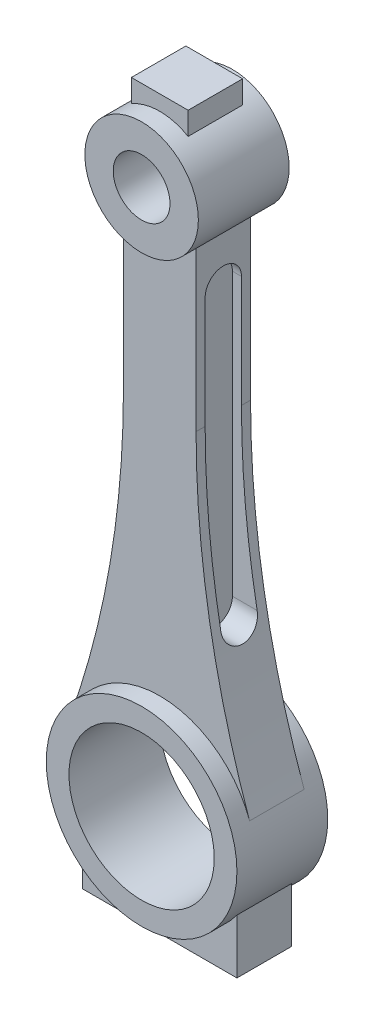
from build123d import *

# Parameters (mm, degrees)
SKETCH1_R             = 21
SKETCH1_R_2           = 16
BOSS_EXTRUDE2_DEPTH   = 10
SKETCH1_R_3           = 12.5
SKETCH1_R_4           = 6.25
BOSS_EXTRUDE2_2_DEPTH = 10
BOSS_EXTRUDE4_DEPTH   = 6
CUT_EXTRUDE1_START    = 6
CUT_EXTRUDE1_DEPTH    = 12


with BuildPart() as part:
    # Sketch1 → Boss-Extrude2 (new body, symmetric)
    with BuildSketch(Plane.XY):
        Circle(SKETCH1_R)
        Circle(SKETCH1_R_2, mode=Mode.SUBTRACT)
    extrude(amount=BOSS_EXTRUDE2_DEPTH, both=True)



with BuildPart() as body_2:
    # Sketch1 → Boss-Extrude2 2 (new body, symmetric)
    with BuildSketch(Plane.XY):
        with Locations((0, 120)):
            Circle(SKETCH1_R_3)
        with Locations((0, 120)):
            Circle(SKETCH1_R_4, mode=Mode.SUBTRACT)
    extrude(amount=BOSS_EXTRUDE2_2_DEPTH, both=True)


with BuildPart() as part_1:
    add(part.part)

    add(body_2.part)  # Boss-Extrude4 merges body 2
    # Sketch1_6 → Boss-Extrude4 (add, symmetric)
    with BuildSketch(Plane.XY):
        with BuildLine():
            Line((-8, 110.395313644), (-8, 75.395313644))
            ThreePointArc((-8, 75.395313644), (-10.96842855, 40.709642053), (-19.787382488, 7.032744434))
            ThreePointArc((-19.787382488, 7.032744434), (0, 21), (19.787382488, 7.032744434))
            ThreePointArc((19.787382488, 7.032744434), (10.96842855, 40.709642053), (8, 75.395313644))
            Line((8, 75.395313644), (8, 110.395313644))
            ThreePointArc((8, 110.395313644), (0, 107.5), (-8, 110.395313644))
        make_face()
        with BuildLine():
            Line((-6.25, 135.825317547), (-6.25, 130.825317547))
            ThreePointArc((-6.25, 130.825317547), (0, 132.5), (6.25, 130.825317547))
            Line((6.25, 130.825317547), (6.25, 135.825317547))
            Line((6.25, 135.825317547), (-6.25, 135.825317547))
        make_face()
        with BuildLine():
            ThreePointArc((17, -12.328828006), (0, -21), (-17, -12.328828006))
            Line((-17, -12.328828006), (-17, -24.328828006))
            Line((-17, -24.328828006), (17, -24.328828006))
            Line((17, -24.328828006), (17, -12.328828006))
        make_face()
    extrude(amount=BOSS_EXTRUDE4_DEPTH, both=True)

    # Sketch2 → Cut-Extrude1 (cut)
    with BuildSketch(Plane(origin=(0, 0, 0), x_dir=(0, 0, -1), z_dir=(1, 0, 0)).offset(CUT_EXTRUDE1_START)):
        with BuildLine():
            Line((4, 100), (4, 38))
            ThreePointArc((4, 38), (0, 34), (-4, 38))
            Line((-4, 38), (-4, 100))
            ThreePointArc((-4, 100), (0, 104), (4, 100))
        make_face()
    cut_extrude1 = extrude(amount=CUT_EXTRUDE1_DEPTH, mode=Mode.SUBTRACT)

    # Mirror1: Cut-Extrude1 across plane
    add(cut_extrude1.mirror(Plane(origin=(0, 0, 0), x_dir=(0, 0, 1), z_dir=(1, 0, 0))), mode=Mode.SUBTRACT)


solid = part_1.part
